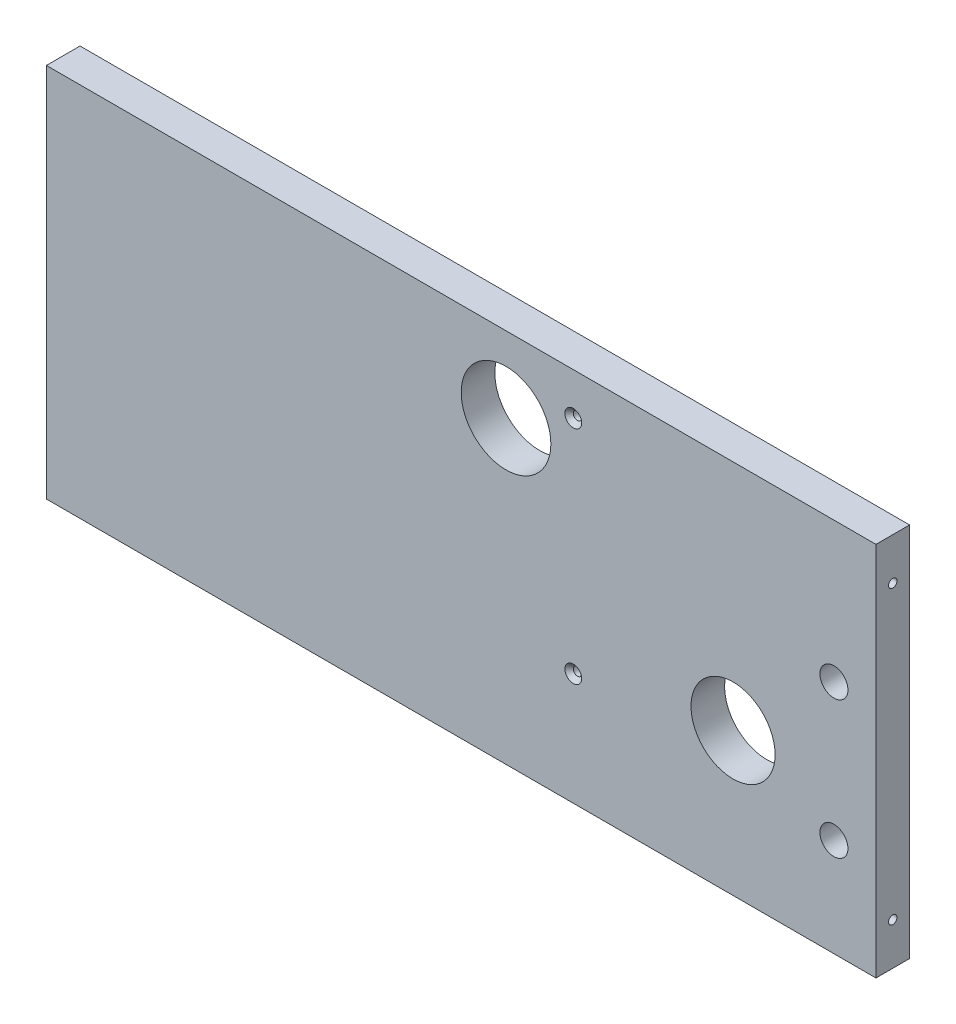
from build123d import *

# Parameters (mm, degrees)
SKETCH1_W           = 296
SKETCH1_H           = 134
SKETCH1_R           = 15
SKETCH1_R_2         = 16
SKETCH1_R_3         = 5
SKETCH1_R_4         = 1.5
BOSS_EXTRUDE1_DEPTH = 12
CUT_EXTRUDE1_START  = 12.189127
SKETCH2_R           = 1.5
CUT_EXTRUDE1_DEPTH  = 20
CUT_EXTRUDE2_START  = 288.189127
SKETCH2_2_R         = 1.5
CUT_EXTRUDE2_DEPTH  = 20.000001
SKETCH5_R           = 1.5
CUT_EXTRUDE5_DEPTH  = 10


with BuildPart() as part:
    # Sketch1 → Boss-Extrude1 (new body)
    with BuildSketch(Plane.XY):
        with Locations((160.18912744, 67)):
            Rectangle(SKETCH1_W, SKETCH1_H)
        with Locations((257.18912744, 51)):
            Circle(SKETCH1_R, mode=Mode.SUBTRACT)
        with Locations((176.18912744, 107)):
            Circle(SKETCH1_R_2, mode=Mode.SUBTRACT)
        with Locations((293.18912744, 84)):
            Circle(SKETCH1_R_3, mode=Mode.SUBTRACT)
        with Locations((200.18912744, 119)):
            Circle(SKETCH1_R_4, mode=Mode.SUBTRACT)
        with Locations((200.18912744, 40)):
            Circle(SKETCH1_R_4, mode=Mode.SUBTRACT)
        with Locations((293.18912744, 35)):
            Circle(SKETCH1_R_3, mode=Mode.SUBTRACT)
    extrude(amount=BOSS_EXTRUDE1_DEPTH)

    # Sketch2 → Cut-Extrude1 (cut)
    with BuildSketch(Plane(origin=(0, 0, 0), x_dir=(0, 0, -1), z_dir=(1, 0, 0)).offset(CUT_EXTRUDE1_START)):
        with Locations((-6, 119)):
            Circle(SKETCH2_R)
        with Locations((-6, 15)):
            Circle(SKETCH2_R)
    extrude(amount=CUT_EXTRUDE1_DEPTH, mode=Mode.SUBTRACT)

    # Sketch2_2 → Cut-Extrude2 (cut)
    with BuildSketch(Plane(origin=(0, 0, 0), x_dir=(0, 0, -1), z_dir=(1, 0, 0)).offset(CUT_EXTRUDE2_START)):
        with Locations((-6, 119)):
            Circle(SKETCH2_2_R)
        with Locations((-6, 15)):
            Circle(SKETCH2_2_R)
    extrude(amount=CUT_EXTRUDE2_DEPTH, mode=Mode.SUBTRACT)

    # Cut-Extrude4 cone 1 section (through the dimple's axis) → Cut-Extrude4 (revolve, cut)
    with BuildSketch(Plane(origin=(200.18912744, 119, 12), x_dir=(0, -1, 0), z_dir=(1, 0, 0))):
        Polygon((0, 0), (3, 0), (0, 3), align=None)
    revolve(axis=Axis((200.18912744, 119, 12), (0, 0, -1)), mode=Mode.SUBTRACT)

    # Cut-Extrude4 cone 2 section (through the dimple's axis) → Cut-Extrude4 cone 2 (revolve, cut)
    with BuildSketch(Plane(origin=(200.18912744, 40, 12), x_dir=(0, -1, 0), z_dir=(1, 0, 0))):
        Polygon((0, 0), (3, 0), (0, 3), align=None)
    revolve(axis=Axis((200.18912744, 40, 12), (0, 0, -1)), mode=Mode.SUBTRACT)

    # Sketch5 → Cut-Extrude5 (cut)
    with BuildSketch(Plane.XY):
        with Locations(Location((221.18912744, 122, 0), (0, 0, 180))):
            Circle(SKETCH5_R)
        with Locations(Location((255.18912744, 122, 0), (0, 0, 180))):
            Circle(SKETCH5_R)
        with Locations(Location((221.18912744, 92, 0), (0, 0, 180))):
            Circle(SKETCH5_R)
        with Locations(Location((255.18912744, 92, 0), (0, 0, 180))):
            Circle(SKETCH5_R)
    extrude(amount=CUT_EXTRUDE5_DEPTH, mode=Mode.SUBTRACT)


solid = part.part
